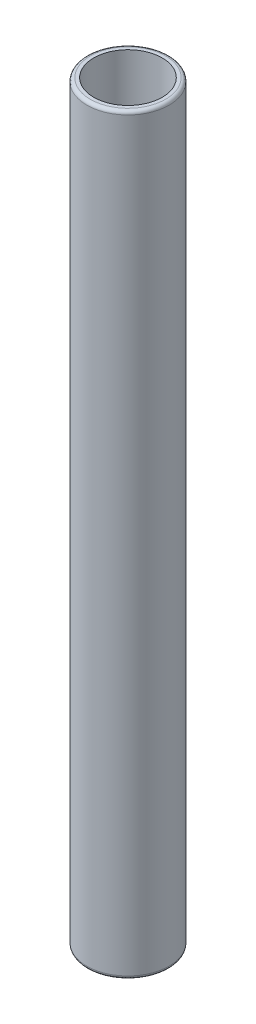
from build123d import *

# Parameters (mm, degrees)
SKETCH1_R           = 6
SKETCH1_R_2         = 5
BOSS_EXTRUDE1_DEPTH = 110
FILLET1_R           = 0.5


with BuildPart() as part:
    # Sketch1 → Boss-Extrude1 (new body)
    with BuildSketch(Plane(origin=(0, 0, 0), x_dir=(1, 0, 0), z_dir=(0, 1, 0))):
        Circle(SKETCH1_R)
        Circle(SKETCH1_R_2, mode=Mode.SUBTRACT)
    extrude(amount=BOSS_EXTRUDE1_DEPTH)

    # Fillet1
    fillet1_edges = [part.edges().sort_by_distance(p)[0] for p in [
        (-6, 0, 0),
        (-6, 110, 0),
    ]]
    fillet(fillet1_edges, radius=FILLET1_R)


solid = part.part
